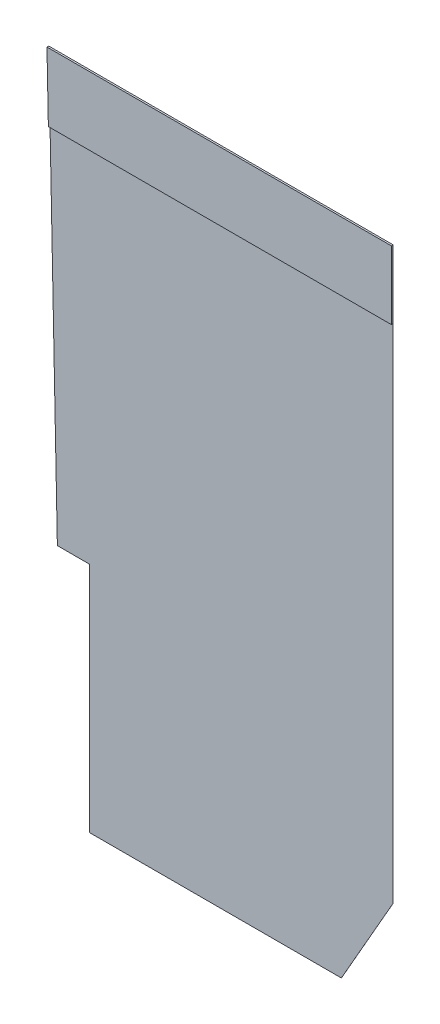
from build123d import *

# Parameters (mm, degrees)
SALIENTE_EXTRUIR1_DEPTH = 1.5875
SALIENTE_EXTRUIR2_DEPTH = 25.4


with BuildPart() as part:
    # Croquis1 → Saliente-Extruir1 (new body)
    with BuildSketch(Plane.XY):
        Polygon((0, 0), (0, 3549.65), (-488.95, 3549.65), (-622.3, 10090.15), (4635.5, 10090.15), (4635.5, 1377.95), (3848.1, 0), align=None)
    extrude(amount=SALIENTE_EXTRUIR1_DEPTH)

    # Croquis2 → Saliente-Extruir2 (add)
    with BuildSketch(Plane.XY.offset(1.5875)):
        Polygon((4635.5, 9048.75), (-601.067572816, 9048.75), (-622.3, 10090.15), (4635.5, 10090.15), align=None)
    extrude(amount=SALIENTE_EXTRUIR2_DEPTH)


solid = part.part
